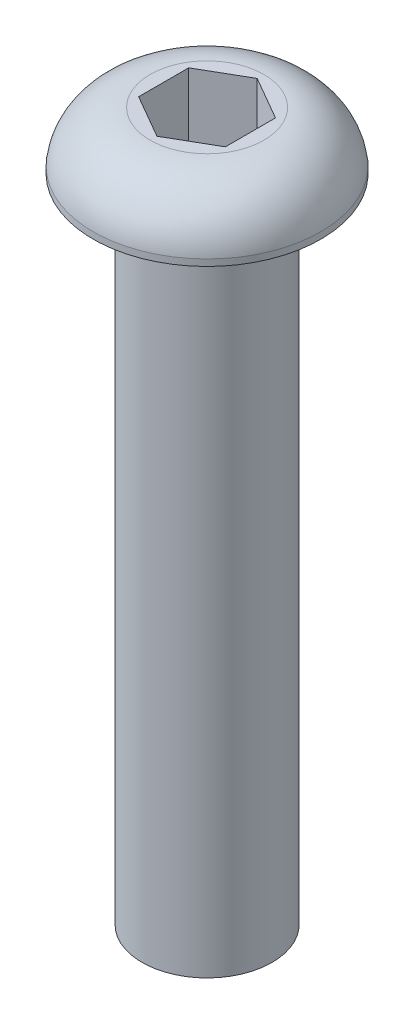
from build123d import *

# Parameters (mm, degrees)
CORTE_EXTRUS_O1_DEPTH = 5


with BuildPart() as part:
    # Esboço1 → Revolução1 (revolve)
    with BuildSketch(Plane.XY):
        with BuildLine():
            Line((0, 32.642087243), (2.625, 32.642087243))
            ThreePointArc((2.625, 32.642087243), (4.383976809, 31.971452659), (5.25, 30.3))
            Line((5.25, 30.3), (5.25, 30))
            Line((5.25, 30), (3, 30))
            Line((3, 30), (3, 0))
            Line((3, 0), (0, 0))
            Line((0, 0), (0, 32.642087243))
        make_face()
    revolve(axis=Axis((0, 0, 0), (0, 1, 0)))

    # Esboço2 → Corte-extrusão1 (cut)
    with BuildSketch(Plane(origin=(0, 32.642087243, 0), x_dir=(1, 0, 0), z_dir=(0, 1, 0))):
        Polygon((0, 2.309401077), (-2, 1.154700538), (-2, -1.154700538), (0, -2.309401077), (2, -1.154700538), (2, 1.154700538), align=None)
    extrude(amount=-CORTE_EXTRUS_O1_DEPTH, mode=Mode.SUBTRACT)


solid = part.part
